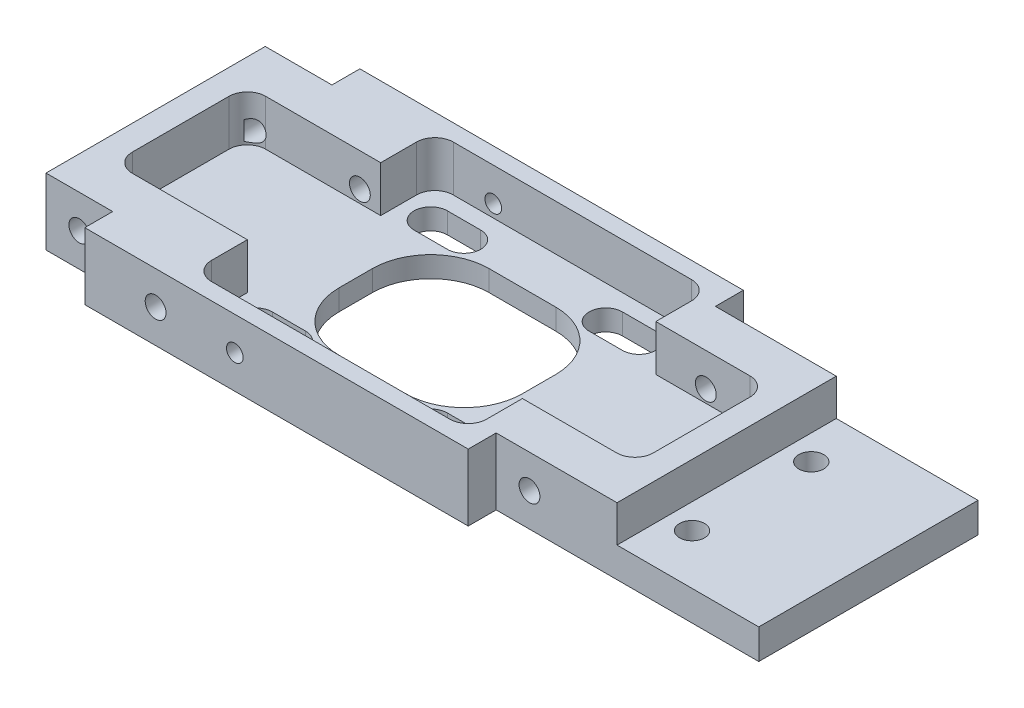
from build123d import *

# Parameters (mm, degrees)
SKETCH_1_R           = 1.5
EXTRUDE_1_DEPTH      = 8
SKETCH_2_W           = 17
SKETCH_2_H           = 26.3
CUT_EXTRUDE_1_DEPTH  = 4.4
CUT_EXTRUDE_3_DEPTH  = 5.5
CUT_EXTRUDE_4_DEPTH  = 3.5
CUT_EXTRUDE_5_DEPTH  = 3.5
SKETCH_9_R           = 1.25
CUT_EXTRUDE_6_DEPTH  = 6
SKETCH_10_R          = 1.25
CUT_EXTRUDE_7_DEPTH  = 6
SKETCH_11_R          = 1.25
CUT_EXTRUDE_8_DEPTH  = 6
SKETCH_12_R          = 1.25
CUT_EXTRUDE_9_DEPTH  = 6
SKETCH_13_R          = 1
SKETCH_13_R_2        = 1.25
CUT_EXTRUDE_10_DEPTH = 46


with BuildPart() as part:
    # Эскиз1 → Бобышка-Вытянуть1 (new body)
    with BuildSketch(Plane(origin=(0, 0, 0), x_dir=(1, 0, 0), z_dir=(0, 1, 0))):
        Polygon((-23, 16.5), (23, 16.5), (23, 13.15), (54.5, 13.15), (54.5, -13.15), (23, -13.15), (23, -16.5), (-23, -16.5), (-23, -13.15), (-31, -13.15), (-31, 13.15), (-23, 13.15), align=None)
        with Locations(Location((40.5, 7.15, 0), (0, 0, 270))):  # turned: the seam where the file's is
            Circle(SKETCH_1_R, mode=Mode.SUBTRACT)
        with Locations(Location((40.5, -7.15, 0), (0, 0, 90))):  # turned: the seam where the file's is
            Circle(SKETCH_1_R, mode=Mode.SUBTRACT)
    extrude(amount=EXTRUDE_1_DEPTH)

    # Эскиз2 → Вырез-Вытянуть1 (cut)
    with BuildSketch(Plane(origin=(0, 8, 0), x_dir=(1, 0, 0), z_dir=(0, 1, 0))):
        with Locations((46, 0)):
            Rectangle(SKETCH_2_W, SKETCH_2_H)
    extrude(amount=-CUT_EXTRUDE_1_DEPTH, mode=Mode.SUBTRACT)

    # Эскиз3 → Вырез-Вытянуть3 (cut)
    with BuildSketch(Plane(origin=(0, 8, 0), x_dir=(1, 0, 0), z_dir=(0, 1, 0))):
        with BuildLine():
            Line((-25.795194039, -8), (-12, -8))
            Line((-12, -8), (-12, -12.295194039))
            ThreePointArc((-12, -12.295194039), (-11.354227285, -13.854227285), (-9.795194039, -14.5))
            Line((-9.795194039, -14.5), (18.795194039, -14.5))
            ThreePointArc((18.795194039, -14.5), (20.354227285, -13.854227285), (21, -12.295194039))
            Line((21, -12.295194039), (21, -8))
            Line((21, -8), (32.295194039, -8))
            ThreePointArc((32.295194039, -8), (33.854227285, -7.354227285), (34.5, -5.795194039))
            Line((34.5, -5.795194039), (34.5, 5.795194039))
            ThreePointArc((34.5, 5.795194039), (33.854227285, 7.354227285), (32.295194039, 8))
            Line((32.295194039, 8), (21, 8))
            Line((21, 8), (21, 12.295194039))
            ThreePointArc((21, 12.295194039), (20.354227285, 13.854227285), (18.795194039, 14.5))
            Line((18.795194039, 14.5), (-9.795194039, 14.5))
            ThreePointArc((-9.795194039, 14.5), (-11.354227285, 13.854227285), (-12, 12.295194039))
            Line((-12, 12.295194039), (-12, 8))
            Line((-12, 8), (-25.795194039, 8))
            ThreePointArc((-25.795194039, 8), (-27.354227285, 7.354227285), (-28, 5.795194039))
            Line((-28, 5.795194039), (-28, -5.795194039))
            ThreePointArc((-28, -5.795194039), (-27.354227285, -7.354227285), (-25.795194039, -8))
        make_face()
    extrude(amount=-CUT_EXTRUDE_3_DEPTH, mode=Mode.SUBTRACT)

    # Эскиз6 → Вырез-Вытянуть4 (cut, through all)
    with BuildSketch(Plane(origin=(0, 2.5, 0), x_dir=(1, 0, 0), z_dir=(0, 1, 0))):
        with BuildLine():
            Line((-7, 2), (-7, -2))
            ThreePointArc((-7, -2), (-4.949747468, -6.949747468), (0, -9))
            Line((0, -9), (8, -9))
            ThreePointArc((8, -9), (12.949747468, -6.949747468), (15, -2))
            Line((15, -2), (15, 2))
            ThreePointArc((15, 2), (12.949747468, 6.949747468), (8, 9))
            Line((8, 9), (0, 9))
            ThreePointArc((0, 9), (-4.949747468, 6.949747468), (-7, 2))
        make_face()
    extrude(amount=-CUT_EXTRUDE_4_DEPTH, mode=Mode.SUBTRACT)

    # Эскиз7 → Вырез-Вытянуть5 (cut, through all)
    with BuildSketch(Plane(origin=(0, 2.5, 0), x_dir=(1, 0, 0), z_dir=(0, 1, 0))):
        with BuildLine():
            Line((12.5, 12.5), (16.5, 12.5))
            ThreePointArc((16.5, 12.5), (18.5, 10.5), (16.5, 8.5))
            Line((16.5, 8.5), (12.5, 8.5))
            ThreePointArc((12.5, 8.5), (10.5, 10.5), (12.5, 12.5))
        make_face()
        with BuildLine():
            Line((-4.5, 8.5), (-8.5, 8.5))
            ThreePointArc((-8.5, 8.5), (-10.5, 10.5), (-8.5, 12.5))
            Line((-8.5, 12.5), (-4.5, 12.5))
            ThreePointArc((-4.5, 12.5), (-2.5, 10.5), (-4.5, 8.5))
        make_face()
        with BuildLine():
            Line((12.5, -8.5), (16.5, -8.5))
            ThreePointArc((16.5, -8.5), (18.5, -10.5), (16.5, -12.5))
            Line((16.5, -12.5), (12.5, -12.5))
            ThreePointArc((12.5, -12.5), (10.5, -10.5), (12.5, -8.5))
        make_face()
        with BuildLine():
            Line((-4.5, -8.5), (-8.5, -8.5))
            ThreePointArc((-8.5, -8.5), (-10.5, -10.5), (-8.5, -12.5))
            Line((-8.5, -12.5), (-4.5, -12.5))
            ThreePointArc((-4.5, -12.5), (-2.5, -10.5), (-4.5, -8.5))
        make_face()
    extrude(amount=-CUT_EXTRUDE_5_DEPTH, mode=Mode.SUBTRACT)

    # Эскиз9 → Вырез-Вытянуть6 (cut)
    with BuildSketch(Plane.XY.offset(13.15)):
        with Locations((-27, 4)):
            Circle(SKETCH_9_R)
    extrude(amount=-CUT_EXTRUDE_6_DEPTH, mode=Mode.SUBTRACT)

    # Эскиз10 → Вырез-Вытянуть7 (cut)
    with BuildSketch(Plane(origin=(0, 0, -13.15), x_dir=(-1, 0, 0), z_dir=(0, 0, -1))):
        with Locations(Location((27, 4, 0), (0, 0, 180))):  # turned: the seam where the file's is
            Circle(SKETCH_10_R)
    extrude(amount=-CUT_EXTRUDE_7_DEPTH, mode=Mode.SUBTRACT)

    # Эскиз11 → Вырез-Вытянуть8 (cut)
    with BuildSketch(Plane(origin=(0, 0, -13.15), x_dir=(-1, 0, 0), z_dir=(0, 0, -1))):
        with Locations((-27, 4)):
            Circle(SKETCH_11_R)
    extrude(amount=-CUT_EXTRUDE_8_DEPTH, mode=Mode.SUBTRACT)

    # Эскиз12 → Вырез-Вытянуть9 (cut)
    with BuildSketch(Plane.XY.offset(13.15)):
        with Locations(Location((27, 4, 0), (0, 0, 180))):  # turned: the seam where the file's is
            Circle(SKETCH_12_R)
    extrude(amount=-CUT_EXTRUDE_9_DEPTH, mode=Mode.SUBTRACT)

    # Эскиз13 → Вырез-Вытянуть10 (cut)
    with BuildSketch(Plane.XY.offset(16.5)):
        with Locations((-5, 4)):
            Circle(SKETCH_13_R)
        with Locations((-14.5, 4)):
            Circle(SKETCH_13_R_2)
    extrude(amount=-CUT_EXTRUDE_10_DEPTH, mode=Mode.SUBTRACT)


solid = part.part
